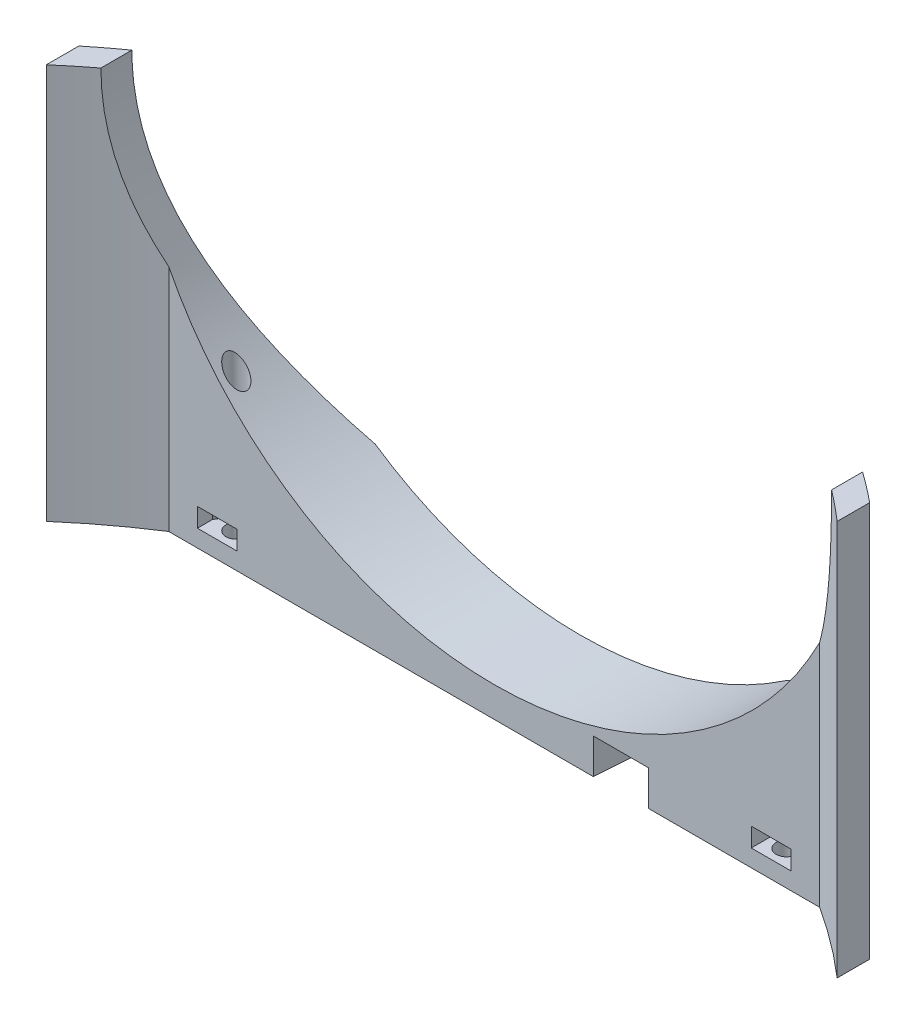
from build123d import *

# Parameters (mm, degrees)
SKETCH1_W           = 92
SKETCH1_H           = 31
BOSS_EXTRUDE1_DEPTH = 46
SKETCH2_R           = 103
SKETCH2_R_2         = 73
CUT_EXTRUDE1_DEPTH  = 47
SKETCH7_R           = 1.2
CUT_EXTRUDE5_DEPTH  = 47
CUT_EXTRUDE2_DEPTH  = 47
SKETCH5_R           = 42.5
CUT_EXTRUDE4_DEPTH  = 17.103780853
CUT_EXTRUDE6_START  = -2
CUT_EXTRUDE6_DEPTH  = 2.2
SKETCH9_W           = 5
SKETCH9_H           = 3.4
CUT_EXTRUDE7_DEPTH  = 17.103780953
CUT_EXTRUDE7_TAPER  = -4


with BuildPart() as part:
    # Sketch1 → Boss-Extrude1 (new body)
    with BuildSketch(Plane(origin=(0, 0, 0), x_dir=(1, 0, 0), z_dir=(0, 1, 0))):
        Rectangle(SKETCH1_W, SKETCH1_H)
    extrude(amount=BOSS_EXTRUDE1_DEPTH)

    # Sketch2 → Cut-Extrude1 (cut, through all)
    with BuildSketch(Plane(origin=(0, 46, 0), x_dir=(1, 0, 0), z_dir=(0, 1, 0))):
        with Locations((0, -53.5)):
            Circle(SKETCH2_R)
        with Locations((0, -53.5)):
            Circle(SKETCH2_R_2, mode=Mode.SUBTRACT)
    extrude(amount=-CUT_EXTRUDE1_DEPTH, mode=Mode.SUBTRACT)

    # Sketch7 → Cut-Extrude5 (cut, through all)
    with BuildSketch(Plane.XZ):
        with Locations((-32, -7.5)):
            Circle(SKETCH7_R)
        with Locations((32, -7.5)):
            Circle(SKETCH7_R)
    extrude(amount=-CUT_EXTRUDE5_DEPTH, mode=Mode.SUBTRACT)

    # Sketch3 → Cut-Extrude2 (cut, through all)
    with BuildSketch(Plane(origin=(0, 46, 0), x_dir=(1, 0, 0), z_dir=(0, 1, 0))):
        with BuildLine():
            Line((-37.855118544, 5.5), (37.855118544, 5.5))
            ThreePointArc((37.855118544, 5.5), (0, -123.6), (-37.855118544, 5.5))
        make_face()
    extrude(amount=-CUT_EXTRUDE2_DEPTH, mode=Mode.SUBTRACT)

    # Sketch5 → Cut-Extrude4 (cut, through all)
    with BuildSketch(Plane(origin=(0, 0, -15.5), x_dir=(-1, 0, 0), z_dir=(0, 0, -1))):
        with Locations((0, 46)):
            Circle(SKETCH5_R)
    extrude(amount=-CUT_EXTRUDE4_DEPTH, mode=Mode.SUBTRACT)

    # Sketch8 → Cut-Extrude6 (cut)
    with BuildSketch(Plane.XZ.offset(CUT_EXTRUDE6_START)):
        Polygon((-34.523561667, -7.229062977), (-33.183568052, -9.55), (-30.816431948, -9.55), (-29.904759513, -7.970937023), (-29.904759513, -4.97225781), (-34.523561667, -4.97225781), align=None)
        Polygon((29.904759513, -4.97225781), (29.904759513, -7.970937023), (30.816431948, -9.55), (33.183568052, -9.55), (34.523561667, -7.229062977), (34.523561667, -4.97225781), align=None)
    extrude(amount=-CUT_EXTRUDE6_DEPTH, mode=Mode.SUBTRACT)

    # Sketch9 → Cut-Extrude7 (cut, through all)
    with BuildSketch(Plane(origin=(0, 0, -15.5), x_dir=(-1, 0, 0), z_dir=(0, 0, -1))):
        with Locations((-14.732750576, 1.7)):
            Rectangle(SKETCH9_W, SKETCH9_H)
    extrude(amount=-CUT_EXTRUDE7_DEPTH, taper=CUT_EXTRUDE7_TAPER, mode=Mode.SUBTRACT)


solid = part.part
